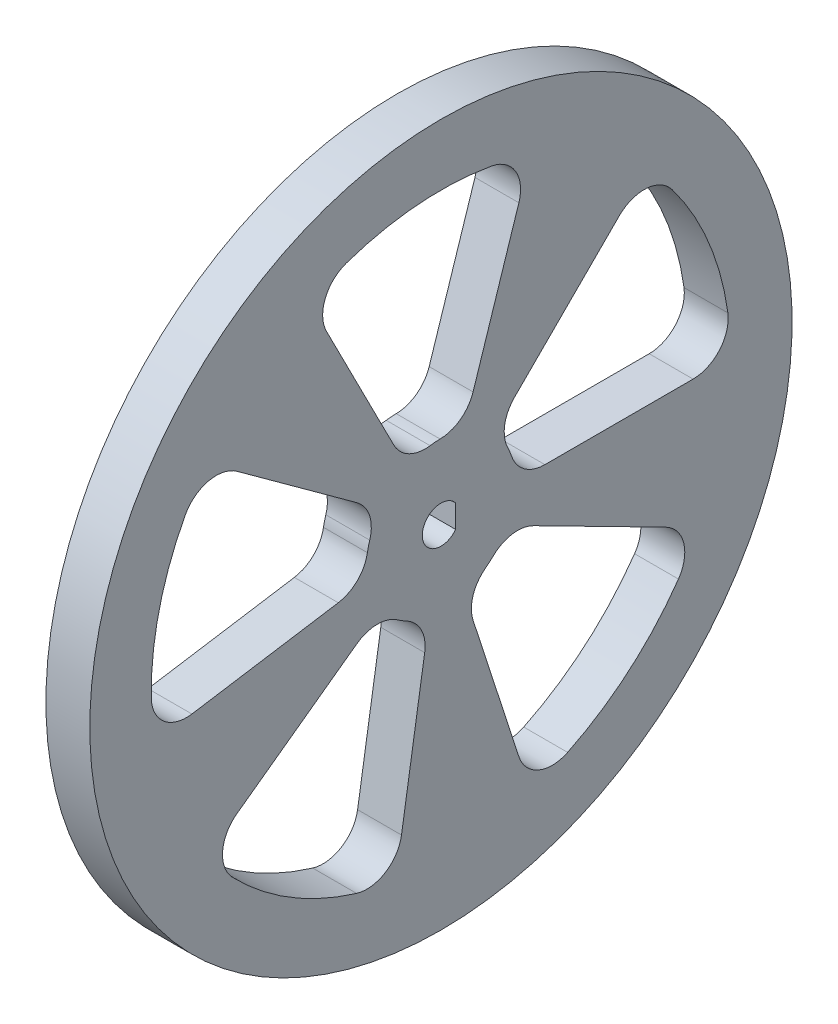
from build123d import *

# Parameters (mm, degrees)
SKETCH3_W           = 5
SKETCH3_H           = 40
CUT_EXTRUDE1_DEPTH  = 5
CIRPATTERN1_COUNT   = 5
SKETCH8_R           = 2.75
BOSS_EXTRUDE1_DEPTH = 3
CUT_EXTRUDE2_REACH  = 10


with BuildPart() as part:
    # Sketch3 → Shape_Roue (revolve)
    with BuildSketch(Plane.XY):
        with Locations((0, 20)):
            Rectangle(SKETCH3_W, SKETCH3_H)
    revolve(axis=Axis((-2.5, 0, 0), (1, 0, 0)))

    # Sketch6 → Cut-Extrude1 (cut)
    with BuildSketch(Plane(origin=(2.5, 0, 0), x_dir=(0, 0, -1), z_dir=(1, 0, 0))):
        with BuildLine():
            Line((8.374067112, 8.374067112), (20.310096012, 20.310096012))
            ThreePointArc((20.310096012, 20.310096012), (23.415046761, 21.472099275), (26.330043569, 19.892933561))
            ThreePointArc((26.330043569, 19.892933561), (30.488024573, 12.628553268), (32.684580575, 4.551724138))
            ThreePointArc((32.684580575, 4.551724138), (31.740005351, 1.373871343), (28.722813233, 0))
            Line((28.722813233, 0), (11.842719282, 0))
            ThreePointArc((11.842719282, 0), (9.510338524, 0.750384638), (8.053049112, 2.72))
            ThreePointArc((8.053049112, 2.72), (7.852976026, 3.252809175), (7.617696081, 3.771035191))
            ThreePointArc((7.617696081, 3.771035191), (7.255426928, 6.194222796), (8.374067112, 8.374067112))
        make_face()
    cut_extrude1 = extrude(amount=-CUT_EXTRUDE1_DEPTH, mode=Mode.SUBTRACT)

    # CirPattern1: Cut-Extrude1 ×5 about axis
    cirpattern1_axis = Axis((0, 0, 0), (1, 0, 0))
    for i in range(1, CIRPATTERN1_COUNT):
        add(cut_extrude1.rotate(cirpattern1_axis, i * 360 / CIRPATTERN1_COUNT), mode=Mode.SUBTRACT)

    # Sketch8 → Boss-Extrude1 (add)
    with BuildSketch(Plane(origin=(-2.5, 0, 0), x_dir=(0, 0, -1), z_dir=(1, 0, 0))):
        Circle(SKETCH8_R)
    extrude(amount=-BOSS_EXTRUDE1_DEPTH)

    # Sketch7 → Cut-Extrude2 (cut, up to next)
    with BuildSketch(Plane(origin=(2.5, 0, 0), x_dir=(0, 0, -1), z_dir=(1, 0, 0)), mode=Mode.PRIVATE) as cut_extrude2_sk1:
        with BuildLine():
            Line((1.675, 1.307669683), (1.675, -1.307669683))
            ThreePointArc((1.675, -1.307669683), (-2.125, 0), (1.675, 1.307669683))
        make_face()
    cut_extrude2_tool1 = extrude(cut_extrude2_sk1.sketch, amount=-CUT_EXTRUDE2_REACH, mode=Mode.PRIVATE) & part.part
    add(cut_extrude2_tool1.solids().sort_by_distance((2.5, 0, 0.111388))[0], mode=Mode.SUBTRACT)


solid = part.part
